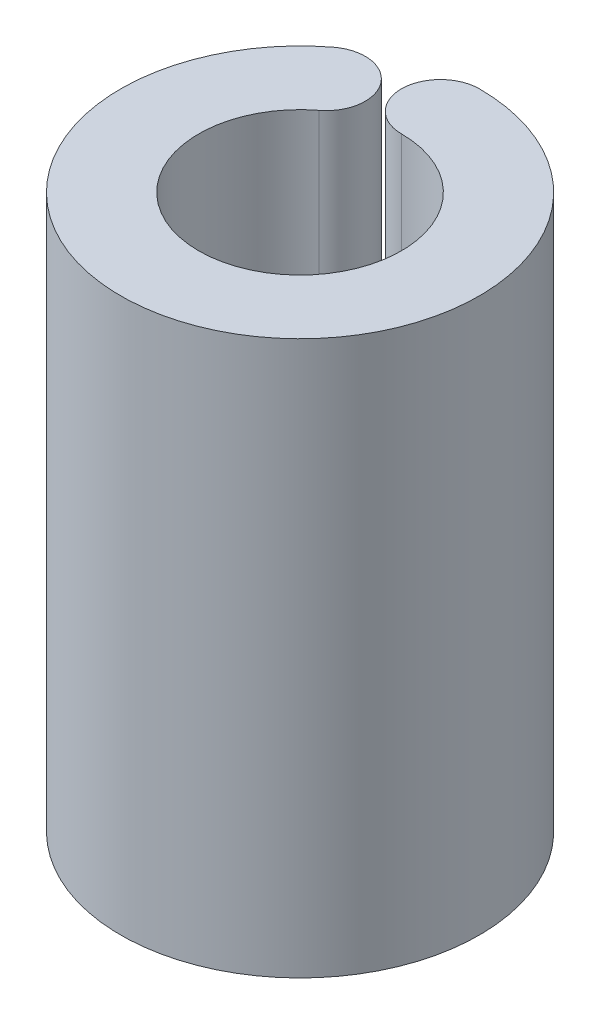
from build123d import *

# Parameters (mm, degrees)
BOSS_EXTRUDE1_DEPTH = 14.2


with BuildPart() as part:
    # Sketch1 → Boss-Extrude1 (new body)
    with BuildSketch(Plane(origin=(0, 0, 0), x_dir=(1, 0, 0), z_dir=(0, 1, 0))):
        with BuildLine():
            ThreePointArc((0, 2.6), (0.833935879, -2.4626309), (-1.579750972, 2.065039192))
            ThreePointArc((-1.579750972, 2.065039192), (-1.393101657, 3.466881563), (-2.794944028, 3.653530879))
            ThreePointArc((-2.794944028, 3.653530879), (1.475425016, -4.356962362), (0, 4.6))
            ThreePointArc((0, 4.6), (-1, 3.6), (0, 2.6))
        make_face()
    extrude(amount=BOSS_EXTRUDE1_DEPTH)


solid = part.part
